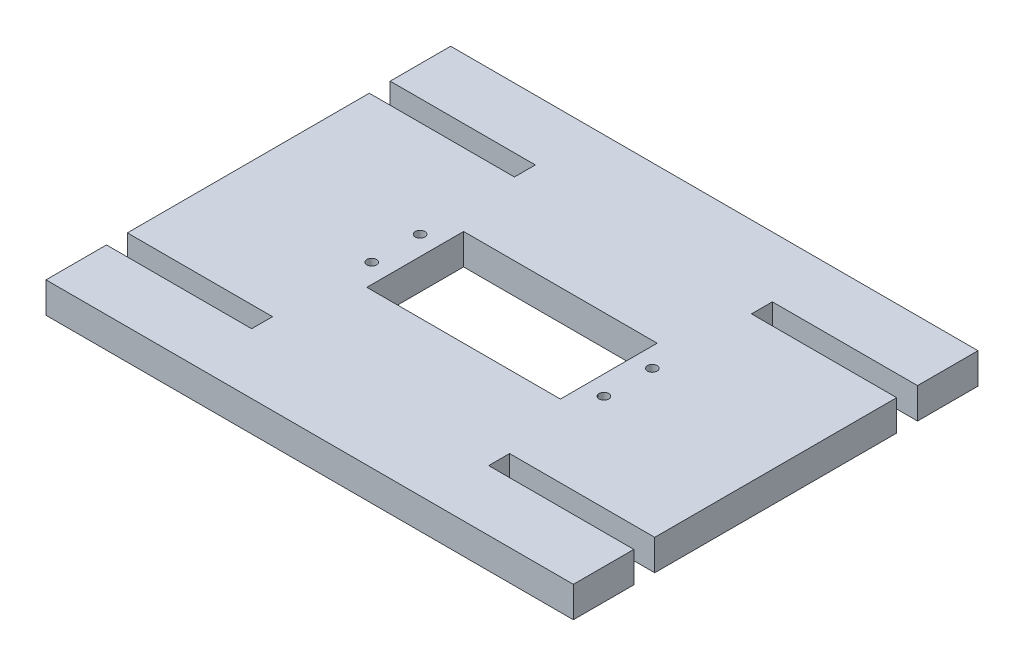
from build123d import *

# Parameters (mm, degrees)
MAIN_SHAPE_DEPTH                            = 6.35
SKETCH2_W                                   = 40
SKETCH2_H                                   = 20
CUT_FOR_SERVO_MOUNTING_HOLE_LOCATIONS_DEPTH = 138.536551491
F_3_48_TAPPED_HOLE1_D                       = 1.9939
F_3_48_TAPPED_HOLE1_DEPTH                   = 7.67
F_3_48_TAPPED_HOLE1_TIP                     = 0.599027994


with BuildPart() as part:
    # Sketch1 → main shape (new body)
    with BuildSketch(Plane(origin=(0, 0, 0), x_dir=(1, 0, 0), z_dir=(0, 1, 0))):
        Polygon((0, 66.818), (0, 16.818), (30, 16.818), (30, 12.5), (0, 12.5), (0, 0), (109, 0), (109, 12.5), (79, 12.5), (79, 16.818), (109, 16.818), (109, 66.818), (79, 66.818), (79, 71.136), (109, 71.136), (109, 83.636), (0, 83.636), (0, 71.136), (30, 71.136), (30, 66.818), align=None)
    extrude(amount=MAIN_SHAPE_DEPTH)

    # Sketch2 → cut for servo _ mounting hole locations (cut, through all)
    with BuildSketch(Plane(origin=(0, 6.35, 0), x_dir=(1, 0, 0), z_dir=(0, 1, 0))):
        with Locations((54.5, 41.818)):
            Rectangle(SKETCH2_W, SKETCH2_H)
    extrude(amount=-CUT_FOR_SERVO_MOUNTING_HOLE_LOCATIONS_DEPTH, mode=Mode.SUBTRACT)

    # 3-48 Tapped Hole1
    with Locations(Plane(origin=(0, 6.35, 0), x_dir=(-1, 0, 0), z_dir=(0, 1, 0))):
        with Locations((-30.5, -36.818), (-30.5, -46.818), (-78.5, -36.818), (-78.5, -46.818)):
            Hole(F_3_48_TAPPED_HOLE1_D / 2, depth=F_3_48_TAPPED_HOLE1_DEPTH)
            with Locations((0, 0, -(F_3_48_TAPPED_HOLE1_DEPTH + F_3_48_TAPPED_HOLE1_TIP / 2))):  # 118° drill point
                Cone(0, F_3_48_TAPPED_HOLE1_D / 2, F_3_48_TAPPED_HOLE1_TIP, mode=Mode.SUBTRACT)


solid = part.part
